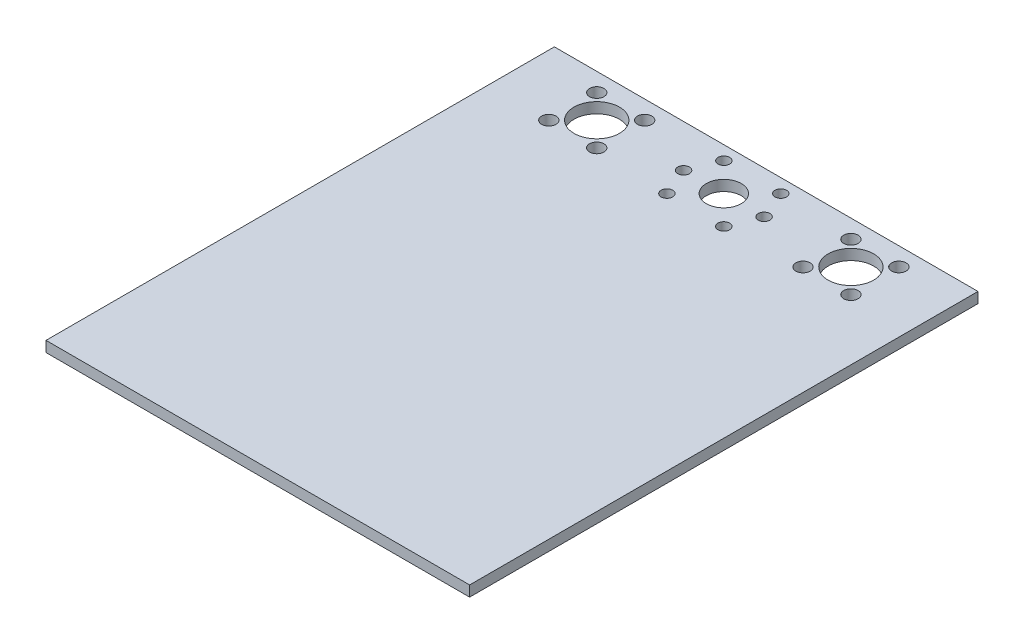
from build123d import *

# Parameters (mm, degrees)
SKETCH1_W           = 200
SKETCH1_H           = 240
BOSS_EXTRUDE1_DEPTH = 5
SKETCH3_R           = 8.25
CUT_EXTRUDE1_DEPTH  = 6
SKETCH4_R           = 2.75
CUT_EXTRUDE2_DEPTH  = 6
SKETCH5_R           = 10.75
CUT_EXTRUDE4_DEPTH  = 6
SKETCH6_R           = 3.4
CUT_EXTRUDE5_DEPTH  = 6


with BuildPart() as part:
    # Sketch1 → Boss-Extrude1 (new body)
    with BuildSketch(Plane(origin=(0, 0, 0), x_dir=(1, 0, 0), z_dir=(0, 1, 0))):
        Rectangle(SKETCH1_W, SKETCH1_H)
    extrude(amount=BOSS_EXTRUDE1_DEPTH)

    # Sketch3 → Cut-Extrude1 (cut, through all)
    with BuildSketch(Plane(origin=(0, 5, 0), x_dir=(1, 0, 0), z_dir=(0, 1, 0))):
        with Locations((0, 100)):
            Circle(SKETCH3_R)
    extrude(amount=-CUT_EXTRUDE1_DEPTH, mode=Mode.SUBTRACT)

    # Sketch4 → Cut-Extrude2 (cut, through all)
    with BuildSketch(Plane(origin=(0, 5, 0), x_dir=(1, 0, 0), z_dir=(0, 1, 0))):
        with Locations((19, 100)):
            Circle(SKETCH4_R)
        with Locations((13.435028843, 113.435028843)):
            Circle(SKETCH4_R)
        with Locations((13.435028843, 86.564971157)):
            Circle(SKETCH4_R)
        with Locations((-13.435028843, 86.564971157)):
            Circle(SKETCH4_R)
        with Locations((-19, 100)):
            Circle(SKETCH4_R)
        with Locations((-13.435028843, 113.435028843)):
            Circle(SKETCH4_R)
    extrude(amount=-CUT_EXTRUDE2_DEPTH, mode=Mode.SUBTRACT)

    # Sketch5 → Cut-Extrude4 (cut, through all)
    with BuildSketch(Plane(origin=(0, 5, 0), x_dir=(1, 0, 0), z_dir=(0, 1, 0))):
        with Locations((-60, 100)):
            Circle(SKETCH5_R)
        with Locations((60, 100)):
            Circle(SKETCH5_R)
    extrude(amount=-CUT_EXTRUDE4_DEPTH, mode=Mode.SUBTRACT)

    # Sketch6 → Cut-Extrude5 (cut, through all)
    with BuildSketch(Plane(origin=(0, 5, 0), x_dir=(1, 0, 0), z_dir=(0, 1, 0))):
        with Locations((-48.686291501, 111.313708499)):
            Circle(SKETCH6_R)
        with Locations((-48.686291501, 88.686291501)):
            Circle(SKETCH6_R)
        with Locations((-71.313708499, 88.686291501)):
            Circle(SKETCH6_R)
        with Locations((-71.313708499, 111.313708499)):
            Circle(SKETCH6_R)
    cut_extrude5 = extrude(amount=-CUT_EXTRUDE5_DEPTH, mode=Mode.SUBTRACT)

    # Mirror1: Cut-Extrude5 across plane
    add(cut_extrude5.mirror(Plane(origin=(0, 0, 0), x_dir=(0, 0, 1), z_dir=(1, 0, 0))), mode=Mode.SUBTRACT)


solid = part.part
